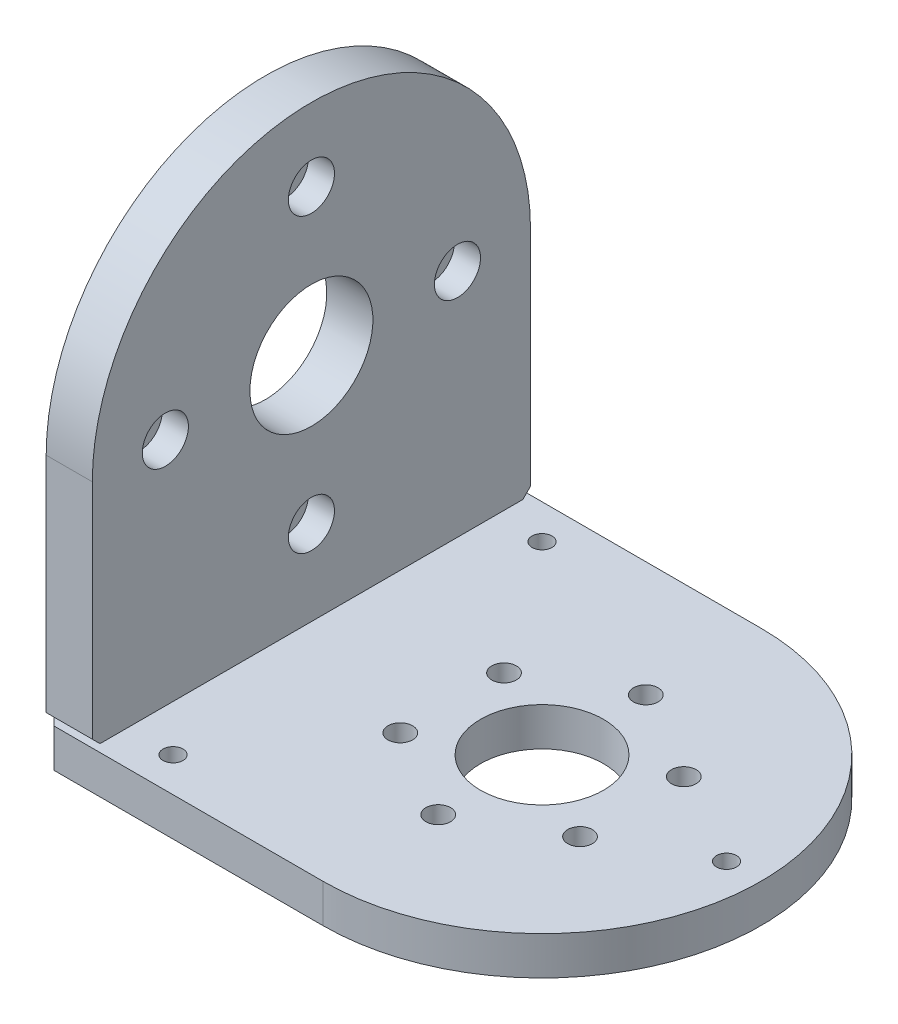
from build123d import *

# Parameters (mm, degrees)
SKETCH_1_W                    = 66
SKETCH_1_H                    = 57
EXTRUDE_1_DEPTH               = 5
SKETCH_12_W                   = 57
SKETCH_12_H                   = 60
EXTRUDE_2_DEPTH               = 6
SKETCH_13_R                   = 8
CUT_EXTRUDE_2_DEPTH           = 6
SKETCH_14_R                   = 8
CUT_EXTRUDE_3_DEPTH           = 6
CUT_EXTRUDE_4_DEPTH           = 10
SKETCH_16_R                   = 1.6
CUT_EXTRUDE_5_DEPTH           = 10
SKETCH_18_R                   = 1.7
CUT_EXTRUDE_6_DEPTH           = 5
CHAMFER_1_SIZE                = 1
SKETCH_22_R                   = 1.6
CUT_EXTRUDE_7_DEPTH           = 59.5
CUT_EXTRUDE_7_DEPTH_BACK      = 6
HOLE_WIZARD_M3_1_AT_2_COUNT   = 2
HOLE_WIZARD_M3_1_AT_2_PITCH   = 26.870057685
HOLE_WIZARD_M3_1_AT_3_COUNT   = 2
HOLE_WIZARD_M3_1_AT_3_PITCH   = 38
HOLE_WIZARD_M3_1_AT_4_COUNT   = 2
HOLE_WIZARD_M3_1_AT_4_PITCH   = 26.870057685
HOLE_WIZARD_M3_1_2_AT_2_COUNT = 2
HOLE_WIZARD_M3_1_2_AT_2_PITCH = 22
HOLE_WIZARD_M3_1_2_AT_3_COUNT = 2
HOLE_WIZARD_M3_1_2_AT_3_PITCH = 44
SKETCH_26_R                   = 1.3
CUT_EXTRUDE_8_DEPTH           = 6
CHAMFER_2_SIZE                = 1


with BuildPart() as part:
    # 草图1 → 凸台-拉伸1 (new body)
    with BuildSketch(Plane(origin=(0, 0, 0), x_dir=(1, 0, 0), z_dir=(0, 1, 0))):
        Rectangle(SKETCH_1_W, SKETCH_1_H)
    extrude(amount=EXTRUDE_1_DEPTH)

    # 草图13 → 切除-拉伸2 (cut)
    with BuildSketch(Plane(origin=(0, 5, 0), x_dir=(1, 0, 0), z_dir=(0, 1, 0))):
        with Locations((3, 0)):
            Circle(SKETCH_13_R)
        with BuildLine():
            Line((3, -28.5), (33, -28.5))
            Line((33, -28.5), (33, 28.5))
            Line((33, 28.5), (3, 28.5))
            ThreePointArc((3, 28.5), (31.5, 0), (3, -28.5))
        make_face()
    extrude(amount=-CUT_EXTRUDE_2_DEPTH, mode=Mode.SUBTRACT)

    # 草图16 → 切除-拉伸5 (cut)
    with BuildSketch(Plane.XZ):
        with Locations((3, 13.5)):
            Circle(SKETCH_16_R)
        with Locations((14.691342951, 6.75)):
            Circle(SKETCH_16_R)
        with Locations((14.691342951, -6.75)):
            Circle(SKETCH_16_R)
        with Locations((3, -13.5)):
            Circle(SKETCH_16_R)
        with Locations((-8.691342951, -6.75)):
            Circle(SKETCH_16_R)
        with Locations((-8.691342951, 6.75)):
            Circle(SKETCH_16_R)
    extrude(amount=-CUT_EXTRUDE_5_DEPTH, mode=Mode.SUBTRACT)

    # 草图18 → 切除-拉伸6 (cut)
    with BuildSketch(Plane.XZ):
        with Locations((-30, -22)):
            Circle(SKETCH_18_R)
        with Locations((-30, 22)):
            Circle(SKETCH_18_R)
        with Locations((-30, 0)):
            Circle(SKETCH_18_R)
    extrude(amount=-CUT_EXTRUDE_6_DEPTH, mode=Mode.SUBTRACT)

    # 倒角1
    chamfer_1_edges = [part.edges().sort_by_distance(p)[0] for p in [
        (-33, 2.5, 28.5),
        (-33, 2.5, -28.5),
    ]]
    chamfer(chamfer_1_edges, length=CHAMFER_1_SIZE)

    # 草图26 → 切除-拉伸8 (cut, through all)
    with BuildSketch(Plane(origin=(0, 5, 0), x_dir=(1, 0, 0), z_dir=(0, 1, 0))):
        with Locations((-21, 24)):
            Circle(SKETCH_26_R)
        with Locations((-21, -24)):
            Circle(SKETCH_26_R)
        with Locations((27, 0)):
            Circle(SKETCH_26_R)
    extrude(amount=-CUT_EXTRUDE_8_DEPTH, mode=Mode.SUBTRACT)


with BuildPart() as body_2:
    # 草图12 → 凸台-拉伸2 (new body)
    with BuildSketch(Plane.ZY.offset(33)):
        with Locations((0, 35)):
            Rectangle(SKETCH_12_W, SKETCH_12_H)
    extrude(amount=-EXTRUDE_2_DEPTH)

    # 草图14 → 切除-拉伸3 (cut)
    with BuildSketch(Plane.ZY.offset(33)):
        with Locations((0, 35)):
            Circle(SKETCH_14_R)
    extrude(amount=-CUT_EXTRUDE_3_DEPTH, mode=Mode.SUBTRACT)

    # 草图15 → 切除-拉伸4 (cut)
    with BuildSketch(Plane.ZY.offset(33)):
        with BuildLine():
            Line((28.5, 35), (28.5, 65))
            Line((28.5, 65), (-28.5, 65))
            Line((-28.5, 65), (-28.5, 35))
            ThreePointArc((-28.5, 35), (0, 63.5), (28.5, 35))
        make_face()
    extrude(amount=-CUT_EXTRUDE_4_DEPTH, mode=Mode.SUBTRACT)

    # 草图22 → 切除-拉伸7 (cut, two sides)
    with BuildSketch(Plane(origin=(-27, 0, 0), x_dir=(0, 0, -1), z_dir=(1, 0, 0))) as cut_extrude_7_sk:
        with Locations((0, 54)):
            Circle(SKETCH_22_R)
        with Locations((-19, 35)):
            Circle(SKETCH_22_R)
        with Locations((19, 35)):
            Circle(SKETCH_22_R)
        with Locations((0, 16)):
            Circle(SKETCH_22_R)
    extrude(amount=CUT_EXTRUDE_7_DEPTH, mode=Mode.SUBTRACT)
    extrude(cut_extrude_7_sk.sketch, amount=-CUT_EXTRUDE_7_DEPTH_BACK, mode=Mode.SUBTRACT)

    # 草图23 → Hole Wizard M3 _1 (revolve, cut)
    with BuildSketch(Plane(origin=(-27, 35, -19), x_dir=(0, 0, -1), z_dir=(0, 1, 0))):
        Polygon((0, 0), (0, 13.421463052), (1.7, 12.4), (1.7, 3.4), (3, 3.4), (3, 0), align=None)
    hole_wizard_m3_1 = revolve(axis=Axis((-20.65, 35, -19), (-1, 0, 0)), mode=Mode.SUBTRACT)

    # Hole Wizard M3 _1 at 2: Hole Wizard M3 _1 ×2
    with Locations(*[Vector(0, 0.707106781, 0.707106781) * (i * HOLE_WIZARD_M3_1_AT_2_PITCH) for i in range(1, HOLE_WIZARD_M3_1_AT_2_COUNT)]):
        add(hole_wizard_m3_1, mode=Mode.SUBTRACT)

    # Hole Wizard M3 _1 at 3: Hole Wizard M3 _1 ×2
    with Locations(*[(0, 0, i * HOLE_WIZARD_M3_1_AT_3_PITCH) for i in range(1, HOLE_WIZARD_M3_1_AT_3_COUNT)]):
        add(hole_wizard_m3_1, mode=Mode.SUBTRACT)

    # Hole Wizard M3 _1 at 4: Hole Wizard M3 _1 ×2
    with Locations(*[Vector(0, -0.707106781, 0.707106781) * (i * HOLE_WIZARD_M3_1_AT_4_PITCH) for i in range(1, HOLE_WIZARD_M3_1_AT_4_COUNT)]):
        add(hole_wizard_m3_1, mode=Mode.SUBTRACT)

    # 草图25 → Hole Wizard M3 _1 2 (revolve, cut)
    with BuildSketch(Plane(origin=(-30, 5, -22), x_dir=(0, 0, -1), z_dir=(1, 0, 0))):
        Polygon((0, 0), (0, 7.751075774), (1.25, 7), (1.25, 0), align=None)
    hole_wizard_m3_1_2 = revolve(axis=Axis((-30, -1.35, -22), (0, 1, 0)), mode=Mode.SUBTRACT)

    # Hole Wizard M3 _1 2 at 2: Hole Wizard M3 _1 2 ×2
    with Locations(*[(0, 0, i * HOLE_WIZARD_M3_1_2_AT_2_PITCH) for i in range(1, HOLE_WIZARD_M3_1_2_AT_2_COUNT)]):
        add(hole_wizard_m3_1_2, mode=Mode.SUBTRACT)

    # Hole Wizard M3 _1 2 at 3: Hole Wizard M3 _1 2 ×2
    with Locations(*[(0, 0, i * HOLE_WIZARD_M3_1_2_AT_3_PITCH) for i in range(1, HOLE_WIZARD_M3_1_2_AT_3_COUNT)]):
        add(hole_wizard_m3_1_2, mode=Mode.SUBTRACT)

    # 倒角2
    chamfer_2_edges = [body_2.edges().sort_by_distance(p)[0] for p in [
        (-30, 5, 28.5),
        (-30, 5, -28.5),
    ]]
    chamfer(chamfer_2_edges, length=CHAMFER_2_SIZE)


solid = Compound([part.part, body_2.part])
